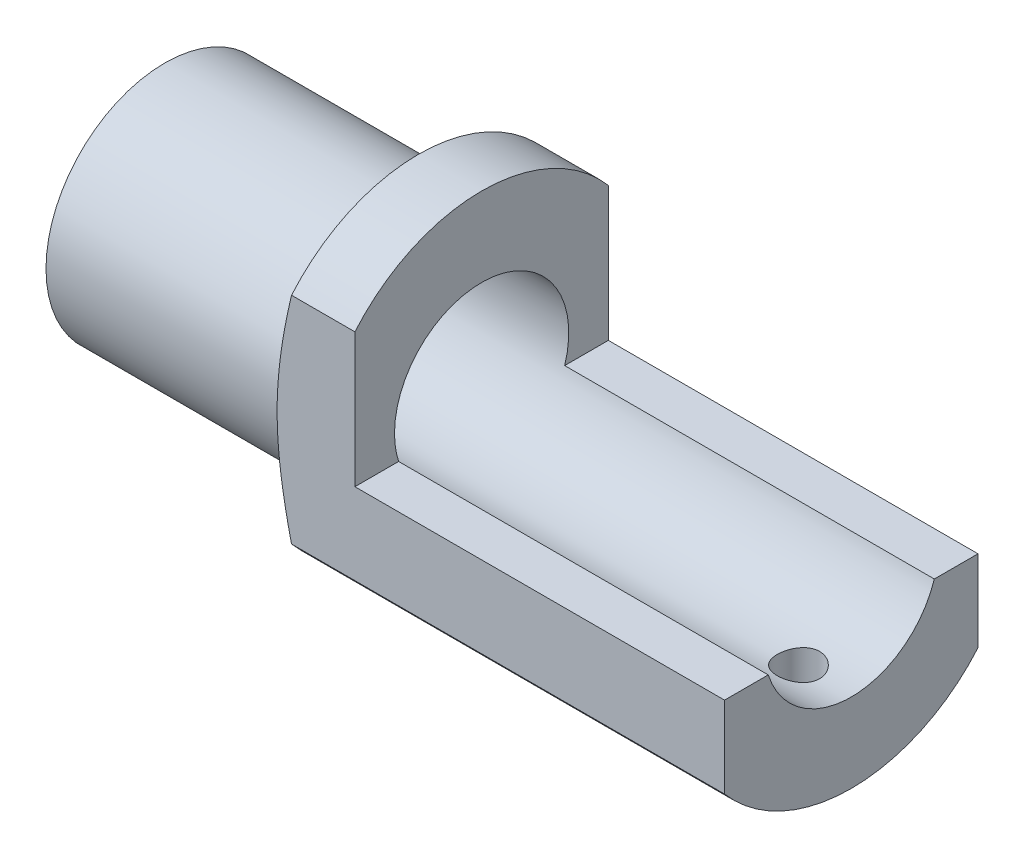
from build123d import *

# Parameters (mm, degrees)
CUT_EXTRUDE_1_DEPTH      = 7
CHAMFER_1_SIZE           = 0.3
CHAMFER_1_SIZE2          = 0.824243226
SKETCH_3_R               = 0.4
CUT_EXTRUDE_2_DEPTH      = 10
CUT_EXTRUDE_3_DEPTH      = 7.0000001
CUT_EXTRUDE_3_DEPTH_BACK = 8.0000001


with BuildPart() as part:
    # Эскиз1 → Повернуть1 (revolve)
    with BuildSketch(Plane.XY):
        Polygon((0, 1.65), (13, 1.65), (13, 3.15), (4.5, 3.15), (4.5, 2.25), (0, 2.25), align=None)
    revolve(axis=Axis((0, 0, 0), (1, 0, 0)))

    # Эскиз2 → Вырез-Вытянуть1 (cut)
    with BuildSketch(Plane(origin=(13, 0, 0), x_dir=(0, 0, -1), z_dir=(1, 0, 0))):
        Polygon((-27.602946028, -0.5), (-3.110064308, -0.5), (3.110064308, -0.5), (27.602946028, -0.5), (27.602946028, 48.485763441), (-27.602946028, 48.485763441), align=None)
    extrude(amount=-CUT_EXTRUDE_1_DEPTH, mode=Mode.SUBTRACT)

    # Фаска1
    chamfer_1_edges = [part.edges().sort_by_distance(p)[0] for p in [
        (4.5, -3.15, 0),
    ]]
    chamfer_1_side = [part.faces().sort_by_distance(p)[0] for p in [
        (8.75, -3.15, 0),
    ]]
    chamfer(chamfer_1_edges, length=CHAMFER_1_SIZE, length2=CHAMFER_1_SIZE2, reference=chamfer_1_side[0])

    # Эскиз3 → Вырез-Вытянуть2 (cut)
    with BuildSketch(Plane(origin=(0, -0.5, 0), x_dir=(1, 0, 0), z_dir=(0, 1, 0))):
        with Locations((12, 0)):
            Circle(SKETCH_3_R)
    extrude(amount=-CUT_EXTRUDE_2_DEPTH, mode=Mode.SUBTRACT)

    # Эскиз4 → Вырез-Вытянуть3 (cut, two sides)
    with BuildSketch(Plane.ZY.offset(-6)) as cut_extrude_3_sk:
        with BuildLine():
            ThreePointArc((-3.110064308, -0.5), (-3.033707684, 0.84800807), (-2.4, 2.040220576))
            Line((-2.4, 2.040220576), (-3.699342341, 2.040220576))
            Line((-3.699342341, 2.040220576), (-3.699342341, -2.040220576))
            Line((-3.699342341, -2.040220576), (-2.4, -2.040220576))
            Line((-2.4, -2.040220576), (-2.4, -0.5))
            Line((-2.4, -0.5), (-3.110064308, -0.5))
        make_face()
        with BuildLine():
            Line((4.02795857, 2.040220576), (2.4, 2.040220576))
            ThreePointArc((2.4, 2.040220576), (3.033707684, 0.84800807), (3.110064308, -0.5))
            Line((3.110064308, -0.5), (2.4, -0.5))
            Line((2.4, -0.5), (2.4, -2.040220576))
            Line((2.4, -2.040220576), (4.02795857, -2.040220576))
            Line((4.02795857, -2.040220576), (4.02795857, 2.040220576))
        make_face()
        with BuildLine():
            Line((-2.4, -0.5), (-2.4, 2.040220576))
            ThreePointArc((-2.4, 2.040220576), (-3.033707684, 0.84800807), (-3.110064308, -0.5))
            Line((-3.110064308, -0.5), (-2.4, -0.5))
        make_face()
        with BuildLine():
            ThreePointArc((3.110064308, -0.5), (3.033707684, 0.84800807), (2.4, 2.040220576))
            Line((2.4, 2.040220576), (2.4, -0.5))
            Line((2.4, -0.5), (3.110064308, -0.5))
        make_face()
    extrude(amount=CUT_EXTRUDE_3_DEPTH, mode=Mode.SUBTRACT)
    extrude(cut_extrude_3_sk.sketch, amount=-CUT_EXTRUDE_3_DEPTH_BACK, mode=Mode.SUBTRACT)


solid = part.part
